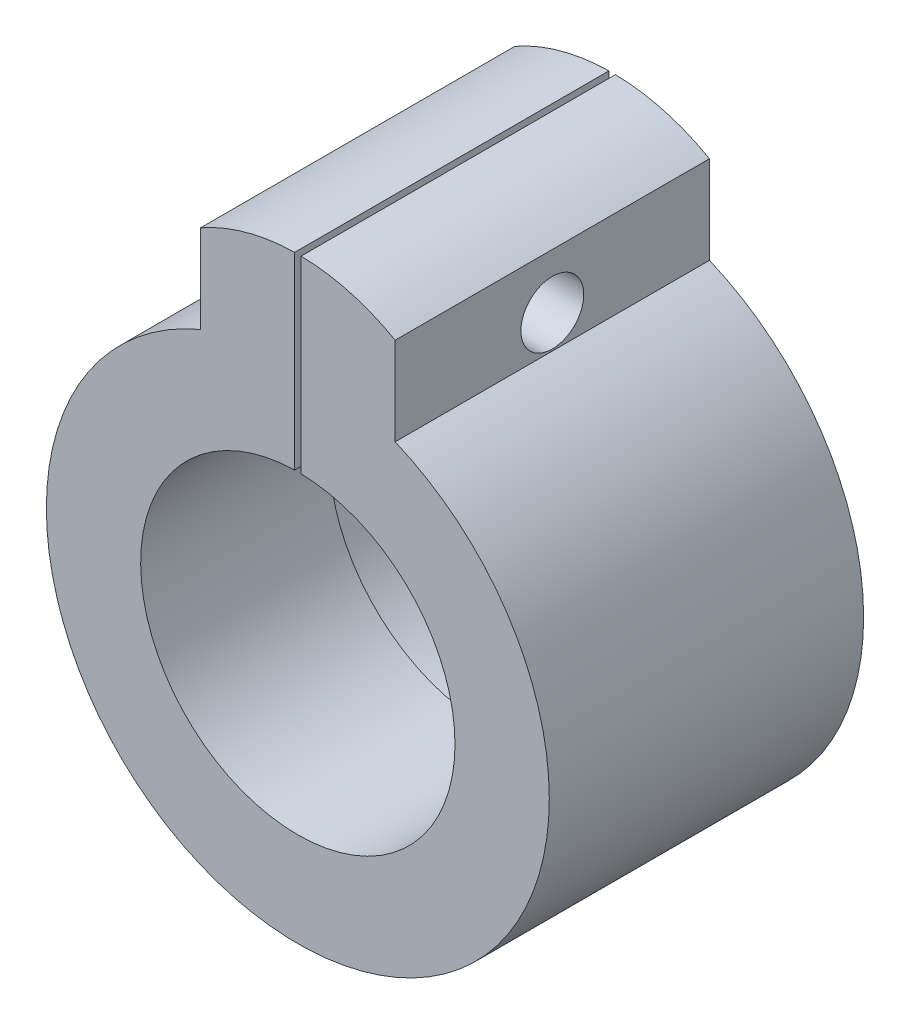
from build123d import *

# Parameters (mm, degrees)
SKETCH_1_R          = 3.5
SKETCH_1_R_2        = 13
EXTRUDE_2_DEPTH     = 10
SKETCH_2_R          = 12.5
EXTRUDE_3_DEPTH     = 15
SKETCH_3_W          = 0.517195108
SKETCH_3_H          = 18.726193104
CUT_EXTRUDE_1_DEPTH = 26
SKETCH_4_R          = 2.5
CUT_EXTRUDE_2_DEPTH = 43.740275714
CUT_EXTRUDE_3_DEPTH = 10


with BuildPart() as part:
    # 草图1 → 凸台-拉伸2 (new body)
    with BuildSketch(Plane.XY):
        with BuildLine():
            Line((-35, -7), (-7.740275714, -18.44147857))
            ThreePointArc((-7.740275714, -18.44147857), (0, -20), (7.740275714, -18.44147857))
            Line((7.740275714, -18.44147857), (35, -7))
            Line((35, -7), (35, 7))
            Line((35, 7), (7.740275714, 18.44147857))
            Line((7.740275714, 18.44147857), (7.740275714, 25.44147857))
            ThreePointArc((7.740275714, 25.44147857), (0, 27.494244152), (-7.740275714, 25.44147857))
            Line((-7.740275714, 25.44147857), (-7.740275714, 18.44147857))
            Line((-7.740275714, 18.44147857), (-35, 7))
            Line((-35, 7), (-35, -7))
        make_face()
        with Locations((-28, 0)):
            Circle(SKETCH_1_R, mode=Mode.SUBTRACT)
        Circle(SKETCH_1_R_2, mode=Mode.SUBTRACT)
        with Locations((28, 0)):
            Circle(SKETCH_1_R, mode=Mode.SUBTRACT)
    extrude(amount=EXTRUDE_2_DEPTH)

    # 草图2 → 凸台-拉伸3 (add)
    with BuildSketch(Plane.XY.offset(10)):
        with BuildLine():
            Line((-7.740275714, 18.44147857), (-7.740275714, 25.44147857))
            ThreePointArc((-7.740275714, 25.44147857), (0, 27.494244152), (7.740275714, 25.44147857))
            Line((7.740275714, 25.44147857), (7.740275714, 18.44147857))
            ThreePointArc((7.740275714, 18.44147857), (0, -20), (-7.740275714, 18.44147857))
        make_face()
        Circle(SKETCH_2_R, mode=Mode.SUBTRACT)
    extrude(amount=EXTRUDE_3_DEPTH)

    # 草图3 → 切除-拉伸1 (cut, through all)
    with BuildSketch(Plane.XY.offset(25)):
        with Locations((0, 21.741202931)):
            Rectangle(SKETCH_3_W, SKETCH_3_H)
    extrude(amount=-CUT_EXTRUDE_1_DEPTH, mode=Mode.SUBTRACT)

    # 草图4 → 切除-拉伸2 (cut, through all)
    with BuildSketch(Plane(origin=(7.740275714, 0, 0), x_dir=(0, 0, -1), z_dir=(1, 0, 0))):
        with Locations((-12.5, 21.086423576)):
            Circle(SKETCH_4_R)
    extrude(amount=-CUT_EXTRUDE_2_DEPTH, mode=Mode.SUBTRACT)

    # 草图6 → 切除-拉伸3 (cut)
    with BuildSketch(Plane.XY.offset(10)):
        with BuildLine():
            Line((-7.740275714, 18.44147857), (-35, 7))
            Line((-35, 7), (-35, -7))
            Line((-35, -7), (-7.740275714, -18.44147857))
            ThreePointArc((-7.740275714, -18.44147857), (-20, 0), (-7.740275714, 18.44147857))
        make_face()
        with BuildLine():
            Line((7.740275714, -18.44147857), (35, -7))
            Line((35, -7), (35, 7))
            Line((35, 7), (7.740275714, 18.44147857))
            ThreePointArc((7.740275714, 18.44147857), (20, 0), (7.740275714, -18.44147857))
        make_face()
    extrude(amount=-CUT_EXTRUDE_3_DEPTH, mode=Mode.SUBTRACT)


solid = part.part
